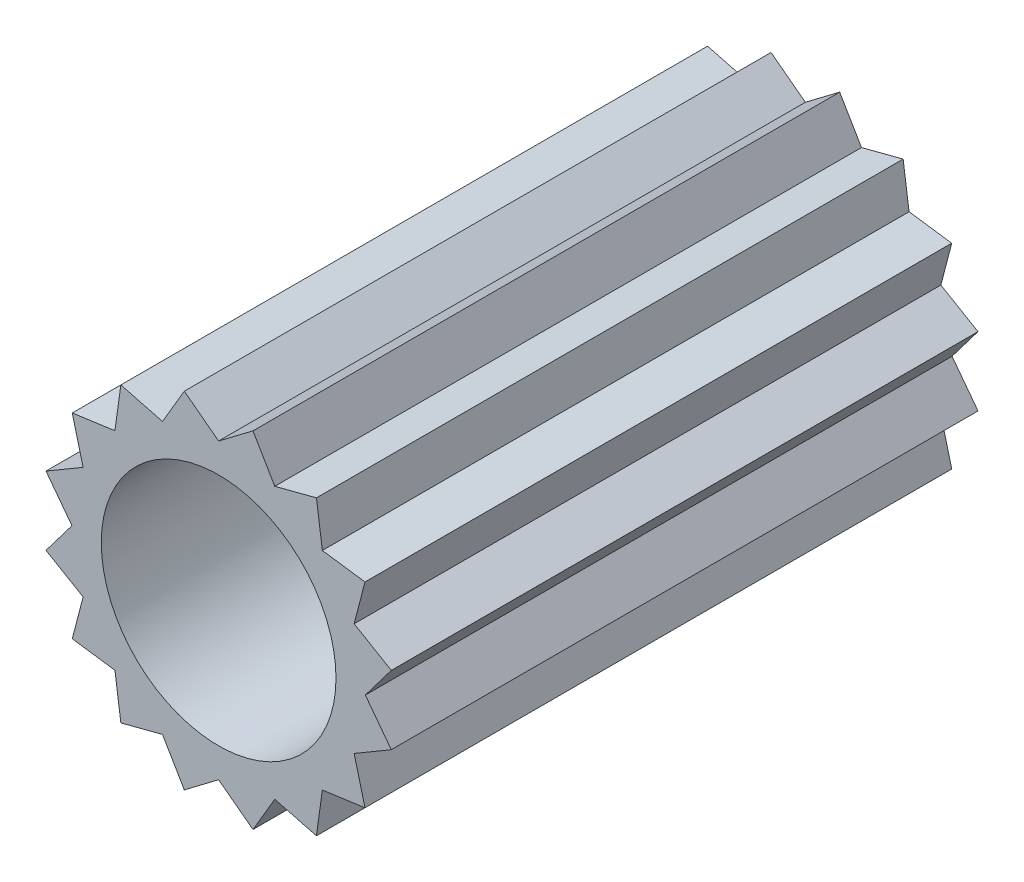
from build123d import *

# Parameters (mm, degrees)
SKETCH2_R           = 2
BOSS_EXTRUDE1_DEPTH = 10


with BuildPart() as part:
    # Sketch2 → Boss-Extrude1 (new body)
    with BuildSketch(Plane.XY):
        Polygon((0, 2.5), (0.585270966, 2.942355841), (0.956708581, 2.309698831), (1.666710699, 2.494408837), (1.767766953, 1.767766953), (2.494408837, 1.666710699), (2.309698831, 0.956708581), (2.942355841, 0.585270966), (2.5, 0), (2.942355841, -0.585270966), (2.309698831, -0.956708581), (2.494408837, -1.666710699), (1.767766953, -1.767766953), (1.666710699, -2.494408837), (0.956708581, -2.309698831), (0.585270966, -2.942355841), (0, -2.5), (-0.585270966, -2.942355841), (-0.956708581, -2.309698831), (-1.666710699, -2.494408837), (-1.767766953, -1.767766953), (-2.494408837, -1.666710699), (-2.309698831, -0.956708581), (-2.942355841, -0.585270966), (-2.5, 0), (-2.942355841, 0.585270966), (-2.309698831, 0.956708581), (-2.494408837, 1.666710699), (-1.767766953, 1.767766953), (-1.666710699, 2.494408837), (-0.956708581, 2.309698831), (-0.585270966, 2.942355841), align=None)
        Circle(SKETCH2_R, mode=Mode.SUBTRACT)
    extrude(amount=BOSS_EXTRUDE1_DEPTH)


solid = part.part
